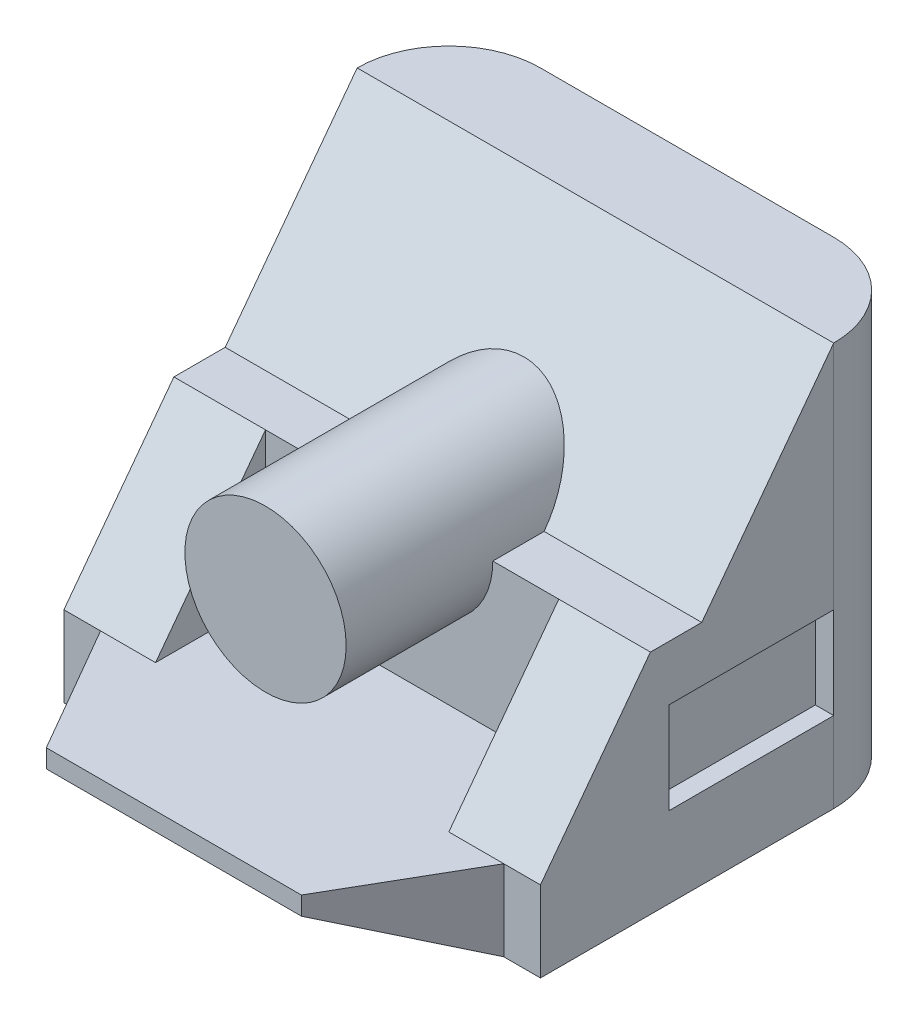
from build123d import *

# Parameters (mm, degrees)
EXTRUDE1_DEPTH             = 130
FILLET1_R                  = 25
EXTRUDE2_DEPTH             = 130
SKETCH3_W                  = 45
SKETCH3_H                  = 25
EXTRUDE3_DEPTH             = 5
SKETCH4_W                  = 80
SKETCH4_H                  = 30
EXTRUDE4_DEPTH             = 40
SKETCH5_R                  = 22
EXTRUDE5_DEPTH             = 40
EXTRUDE5_DIRECTION_2_REACH = 77


with BuildPart() as part:
    # Sketch1 → Extrude1 (new body)
    with BuildSketch(Plane(origin=(0, 0, 0), x_dir=(0, 0, -1), z_dir=(1, 0, 0))):
        Polygon((0, 0), (0, 110), (-25, 110), (-61, 62), (-75, 62), (-105, 22), (-140, 22), (-140, 17), (-105, 0), align=None)
    extrude(amount=EXTRUDE1_DEPTH)

    # Fillet1
    fillet1_edges = [part.edges().sort_by_distance(p)[0] for p in [
        (0, 55, 0),
        (130, 55, 0),
    ]]
    fillet(fillet1_edges, radius=FILLET1_R)

    # Sketch2 → Extrude2 (cut)
    with BuildSketch(Plane(origin=(0, 22, 0), x_dir=(1, 0, 0), z_dir=(0, 1, 0))):
        Polygon((99.792740578, -140), (130, -140), (130, -105), (120, -105), align=None)
        Polygon((10, -105), (30.207259422, -140), (0, -140), (0, -105), align=None)
    extrude(amount=-EXTRUDE2_DEPTH, mode=Mode.SUBTRACT)

    # Sketch3 → Extrude3 (cut)
    with BuildSketch(Plane(origin=(130, 0, 0), x_dir=(0, 0, -1), z_dir=(1, 0, 0))):
        with Locations((-47.5, 34.5)):
            Rectangle(SKETCH3_W, SKETCH3_H)
    extrude(amount=-EXTRUDE3_DEPTH, mode=Mode.SUBTRACT)

    # Sketch4 → Extrude4 (cut)
    with BuildSketch(Plane(origin=(0, 62, 0), x_dir=(1, 0, 0), z_dir=(0, 1, 0))):
        with Locations((65, -90)):
            Rectangle(SKETCH4_W, SKETCH4_H)
    extrude(amount=-EXTRUDE4_DEPTH, mode=Mode.SUBTRACT)

    # Sketch5 → Extrude5 (add)
    with BuildSketch(Plane.XY.offset(75)):
        with Locations((65, 62)):
            Circle(SKETCH5_R)
    extrude(amount=EXTRUDE5_DEPTH)

    # Extrude5 direction 2: up to this face of the body (flat: up to its plane)
    extrude5_direction_2_end = Plane(part.part.faces().sort_by_distance((65, 86, 43))[0])
    # Sketch5 → Extrude5 direction 2 (add, up to the picked face)
    with BuildSketch(Plane.XY.offset(75), mode=Mode.PRIVATE) as extrude5_direction_2_sk1:
        with Locations((65, 62)):
            Circle(SKETCH5_R)
    extrude5_direction_2_tool1 = split(extrude(extrude5_direction_2_sk1.sketch, amount=-EXTRUDE5_DIRECTION_2_REACH, mode=Mode.PRIVATE), bisect_by=extrude5_direction_2_end, keep=Keep.BOTH, mode=Mode.PRIVATE)
    add(extrude5_direction_2_tool1.solids().sort_by(Axis((65, 62, 75), (0, 0, -1)))[0])


solid = part.part
